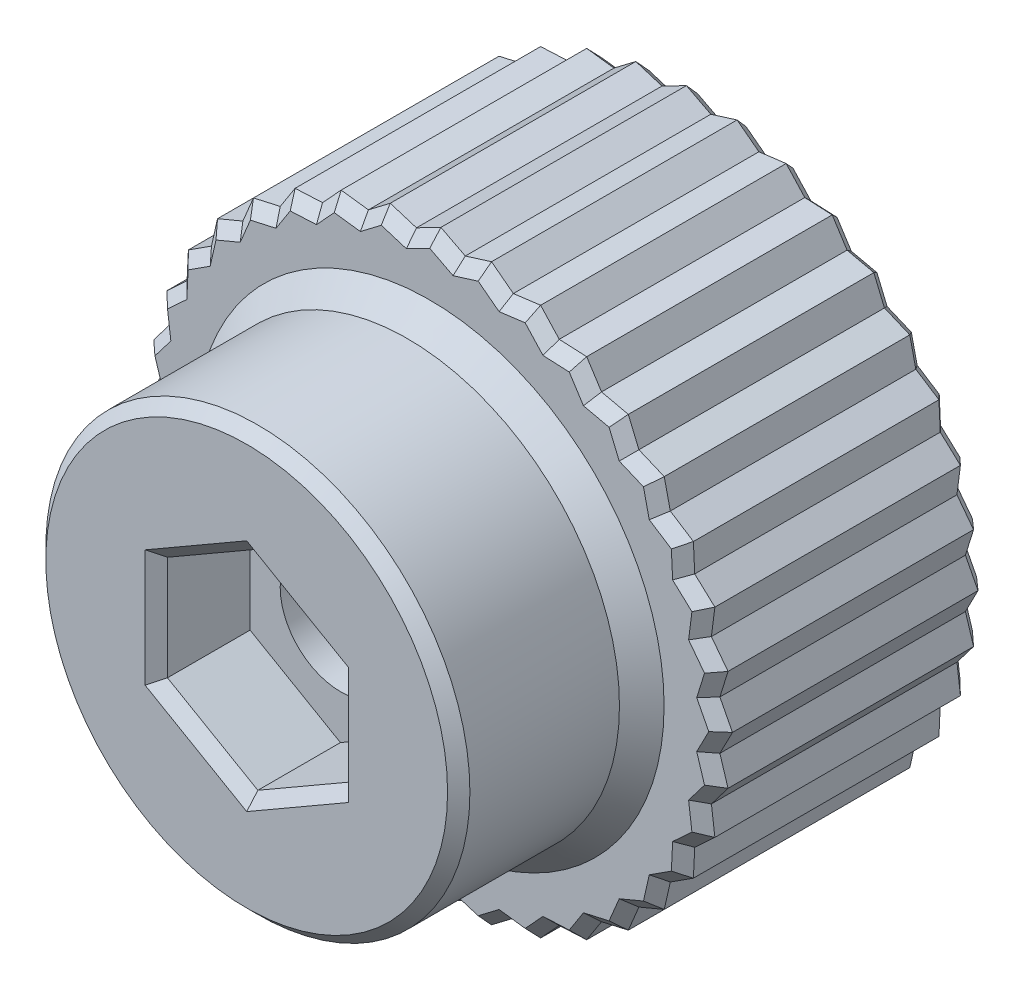
from build123d import *

# Parameters (mm, degrees)
SKETCH1_R           = 12.5
BOSS_EXTRUDE1_DEPTH = 12
SKETCH5_R           = 12.090152216
BOSS_EXTRUDE4_DEPTH = 12
SKETCH8_R           = 9.5
BOSS_EXTRUDE5_DEPTH = 8.2
SKETCH9_R           = 2.7
CUT_EXTRUDE2_DEPTH  = 21.2
SKETCH9_3_R         = 4.4
SKETCH9_3_R_2       = 2.7
CUT_EXTRUDE3_DEPTH  = 5.2
CUT_EXTRUDE4_DEPTH  = 4.2
CHAMFER2_SIZE       = 0.5
CHAMFER3_SIZE       = 1
SKETCH11_R          = 2.7
BOSS_EXTRUDE6_DEPTH = 0.2


with BuildPart() as part:
    # Sketch1 → Boss-Extrude1 (new body)
    with BuildSketch(Plane.XY):
        Circle(SKETCH1_R)
    extrude(amount=BOSS_EXTRUDE1_DEPTH)

    # Sketch5 → Boss-Extrude4 (add)
    with BuildSketch(Plane.XY.offset(12)):
        Polygon((0, 13.063196798), (1.093562728, 12.499479176), (2.268400319, 12.864737486), (3.247460833, 12.119688826), (4.467876441, 12.275389635), (5.302686485, 11.371647864), (6.531598399, 11.313060282), (7.196792691, 10.278085136), (8.396861045, 10.006989317), (8.872227993, 8.872227993), (10.006989317, 8.396861045), (10.278085136, 7.196792691), (11.313060282, 6.531598399), (11.371647864, 5.302686485), (12.275389635, 4.467876441), (12.119688826, 3.247460833), (12.864737486, 2.268400319), (12.499479176, 1.093562728), (13.063196798, 0), (12.499479176, -1.093562728), (12.864737486, -2.268400319), (12.119688826, -3.247460833), (12.275389635, -4.467876441), (11.371647864, -5.302686485), (11.313060282, -6.531598399), (10.278085136, -7.196792691), (10.006989317, -8.396861045), (8.872227993, -8.872227993), (8.396861045, -10.006989317), (7.196792691, -10.278085136), (6.531598399, -11.313060282), (5.302686485, -11.371647864), (4.467876441, -12.275389635), (3.247460833, -12.119688826), (2.268400319, -12.864737486), (1.093562728, -12.499479176), (0, -13.063196798), (-1.093562728, -12.499479176), (-2.268400319, -12.864737486), (-3.247460833, -12.119688826), (-4.467876441, -12.275389635), (-5.302686485, -11.371647864), (-6.531598399, -11.313060282), (-7.196792691, -10.278085136), (-8.396861045, -10.006989317), (-8.872227993, -8.872227993), (-10.006989317, -8.396861045), (-10.278085136, -7.196792691), (-11.313060282, -6.531598399), (-11.371647864, -5.302686485), (-12.275389635, -4.467876441), (-12.119688826, -3.247460833), (-12.864737486, -2.268400319), (-12.499479176, -1.093562728), (-13.063196798, 0), (-12.499479176, 1.093562728), (-12.864737486, 2.268400319), (-12.119688826, 3.247460833), (-12.275389635, 4.467876441), (-11.371647864, 5.302686485), (-11.313060282, 6.531598399), (-10.278085136, 7.196792691), (-10.006989317, 8.396861045), (-8.872227993, 8.872227993), (-8.396861045, 10.006989317), (-7.196792691, 10.278085136), (-6.531598399, 11.313060282), (-5.302686485, 11.371647864), (-4.467876441, 12.275389635), (-3.247460833, 12.119688826), (-2.268400319, 12.864737486), (-1.093562728, 12.499479176), align=None)
        Circle(SKETCH5_R, mode=Mode.SUBTRACT)
    extrude(amount=-BOSS_EXTRUDE4_DEPTH)

    # Sketch8 → Boss-Extrude5 (add)
    with BuildSketch(Plane.XY.offset(12)):
        Circle(SKETCH8_R)
    extrude(amount=BOSS_EXTRUDE5_DEPTH)

    # Sketch9 → Cut-Extrude2 (cut, through all)
    with BuildSketch(Plane(origin=(0, 0, 0), x_dir=(-1, 0, 0), z_dir=(0, 0, -1))):
        Circle(SKETCH9_R)
    extrude(amount=-CUT_EXTRUDE2_DEPTH, mode=Mode.SUBTRACT)

    # Sketch9_3 → Cut-Extrude3 (cut)
    with BuildSketch(Plane(origin=(0, 0, 0), x_dir=(-1, 0, 0), z_dir=(0, 0, -1))):
        Circle(SKETCH9_3_R)
        Circle(SKETCH9_3_R_2, mode=Mode.SUBTRACT)
    extrude(amount=-CUT_EXTRUDE3_DEPTH, mode=Mode.SUBTRACT)

    # Sketch10 → Cut-Extrude4 (cut)
    with BuildSketch(Plane.XY.offset(20.2)):
        Polygon((0, 4.67653718), (-4.05, 2.33826859), (-4.05, -2.33826859), (0, -4.67653718), (4.05, -2.33826859), (4.05, 2.33826859), align=None)
    extrude(amount=-CUT_EXTRUDE4_DEPTH, mode=Mode.SUBTRACT)

    # Chamfer2
    chamfer2_edges = [part.edges().sort_by_distance(p)[0] for p in [
        (-0.546781364, 12.781337987, 12),
        (-1.680981523, 12.682108331, 12),
        (-2.757930576, 12.492213156, 12),
        (-3.857668637, 12.197539231, 12),
        (-4.885281463, 11.82351875, 12),
        (-9.5, 0, 20.2),
        (-5.917142442, 11.342354073, 12),
        (-6.864195545, 10.795572709, 12),
        (-7.796826868, 10.142537226, 12),
        (4.4, 0, 0),
        (-8.634544519, 9.439608655, 12),
        (-9.439608655, 8.634544519, 12),
        (-10.142537226, 7.796826868, 12),
        (2.025, 3.507402885, 20.2),
        (-2.025, 3.507402885, 20.2),
        (-4.05, 0, 20.2),
        (-10.795572709, 6.864195545, 12),
        (-2.025, -3.507402885, 20.2),
        (2.025, -3.507402885, 20.2),
        (4.05, 0, 20.2),
        (-11.342354073, 5.917142442, 12),
        (-11.82351875, 4.885281463, 12),
        (-12.197539231, 3.857668637, 12),
        (-12.492213156, 2.757930576, 12),
        (-12.682108331, 1.680981523, 12),
        (-12.781337987, 0.546781364, 12),
        (-12.781337987, -0.546781364, 12),
        (-12.682108331, -1.680981523, 12),
        (-12.492213156, -2.757930576, 12),
        (-12.197539231, -3.857668637, 12),
        (-11.82351875, -4.885281463, 12),
        (-11.342354073, -5.917142442, 12),
        (-10.795572709, -6.864195545, 12),
        (-10.142537226, -7.796826868, 12),
        (-9.439608655, -8.634544519, 12),
        (-8.634544519, -9.439608655, 12),
        (-7.796826868, -10.142537226, 12),
        (-6.864195545, -10.795572709, 12),
        (-5.917142442, -11.342354073, 12),
        (-4.885281463, -11.82351875, 12),
        (-3.857668637, -12.197539231, 12),
        (-2.757930576, -12.492213156, 12),
        (-1.680981523, -12.682108331, 12),
        (-0.546781364, -12.781337987, 12),
        (0.546781364, -12.781337987, 12),
        (1.680981523, -12.682108331, 12),
        (2.757930576, -12.492213156, 12),
        (3.857668637, -12.197539231, 12),
        (4.885281463, -11.82351875, 12),
        (5.917142442, -11.342354073, 12),
        (6.864195545, -10.795572709, 12),
        (7.796826868, -10.142537226, 12),
        (8.634544519, -9.439608655, 12),
        (9.439608655, -8.634544519, 12),
        (10.142537226, -7.796826868, 12),
        (10.795572709, -6.864195545, 12),
        (11.342354073, -5.917142442, 12),
        (11.82351875, -4.885281463, 12),
        (12.197539231, -3.857668637, 12),
        (12.492213156, -2.757930576, 12),
        (12.682108331, -1.680981523, 12),
        (12.781337987, -0.546781364, 12),
        (12.781337987, 0.546781364, 12),
        (12.682108331, 1.680981523, 12),
        (12.492213156, 2.757930576, 12),
        (12.197539231, 3.857668637, 12),
        (11.82351875, 4.885281463, 12),
        (11.342354073, 5.917142442, 12),
        (10.795572709, 6.864195545, 12),
        (10.142537226, 7.796826868, 12),
        (9.439608655, 8.634544519, 12),
        (8.634544519, 9.439608655, 12),
        (7.796826868, 10.142537226, 12),
        (6.864195545, 10.795572709, 12),
        (5.917142442, 11.342354073, 12),
        (4.885281463, 11.82351875, 12),
        (3.857668637, 12.197539231, 12),
        (2.757930576, 12.492213156, 12),
        (1.680981523, 12.682108331, 12),
        (0.546781364, 12.781337987, 12),
        (-0.546781364, 12.781337987, 0),
        (0.546781364, 12.781337987, 0),
        (1.680981523, 12.682108331, 0),
        (2.757930576, 12.492213156, 0),
        (3.857668637, 12.197539231, 0),
        (4.885281463, 11.82351875, 0),
        (5.917142442, 11.342354073, 0),
        (6.864195545, 10.795572709, 0),
        (7.796826868, 10.142537226, 0),
        (8.634544519, 9.439608655, 0),
        (9.439608655, 8.634544519, 0),
        (10.142537226, 7.796826868, 0),
        (10.795572709, 6.864195545, 0),
        (11.342354073, 5.917142442, 0),
        (11.82351875, 4.885281463, 0),
        (12.197539231, 3.857668637, 0),
        (12.492213156, 2.757930576, 0),
        (12.682108331, 1.680981523, 0),
        (12.781337987, 0.546781364, 0),
        (12.781337987, -0.546781364, 0),
        (12.682108331, -1.680981523, 0),
        (12.492213156, -2.757930576, 0),
        (12.197539231, -3.857668637, 0),
        (11.82351875, -4.885281463, 0),
        (11.342354073, -5.917142442, 0),
        (10.795572709, -6.864195545, 0),
        (10.142537226, -7.796826868, 0),
        (9.439608655, -8.634544519, 0),
        (8.634544519, -9.439608655, 0),
        (7.796826868, -10.142537226, 0),
        (6.864195545, -10.795572709, 0),
        (5.917142442, -11.342354073, 0),
        (4.885281463, -11.82351875, 0),
        (3.857668637, -12.197539231, 0),
        (2.757930576, -12.492213156, 0),
        (1.680981523, -12.682108331, 0),
        (0.546781364, -12.781337987, 0),
        (-0.546781364, -12.781337987, 0),
        (-1.680981523, -12.682108331, 0),
        (-2.757930576, -12.492213156, 0),
        (-3.857668637, -12.197539231, 0),
        (-4.885281463, -11.82351875, 0),
        (-5.917142442, -11.342354073, 0),
        (-6.864195545, -10.795572709, 0),
        (-7.796826868, -10.142537226, 0),
        (-8.634544519, -9.439608655, 0),
        (-9.439608655, -8.634544519, 0),
        (-10.142537226, -7.796826868, 0),
        (-10.795572709, -6.864195545, 0),
        (-11.342354073, -5.917142442, 0),
        (-11.82351875, -4.885281463, 0),
        (-12.197539231, -3.857668637, 0),
        (-12.492213156, -2.757930576, 0),
        (-12.682108331, -1.680981523, 0),
        (-12.781337987, -0.546781364, 0),
        (-12.781337987, 0.546781364, 0),
        (-12.682108331, 1.680981523, 0),
        (-12.492213156, 2.757930576, 0),
        (-12.197539231, 3.857668637, 0),
        (-11.82351875, 4.885281463, 0),
        (-11.342354073, 5.917142442, 0),
        (-10.795572709, 6.864195545, 0),
        (-10.142537226, 7.796826868, 0),
        (-9.439608655, 8.634544519, 0),
        (-8.634544519, 9.439608655, 0),
        (-7.796826868, 10.142537226, 0),
        (-6.864195545, 10.795572709, 0),
        (-5.917142442, 11.342354073, 0),
        (-4.885281463, 11.82351875, 0),
        (-3.857668637, 12.197539231, 0),
        (-2.757930576, 12.492213156, 0),
        (-1.680981523, 12.682108331, 0),
    ]]
    chamfer(chamfer2_edges, length=CHAMFER2_SIZE)

    # Chamfer3
    chamfer3_edges = [part.edges().sort_by_distance(p)[0] for p in [
        (-9.5, 0, 12),
    ]]
    chamfer(chamfer3_edges, length=CHAMFER3_SIZE)

    # Sketch11 → Boss-Extrude6 (add)
    with BuildSketch(Plane(origin=(0, 0, 5.2), x_dir=(-1, 0, 0), z_dir=(0, 0, -1))):
        Circle(SKETCH11_R)
    extrude(amount=-BOSS_EXTRUDE6_DEPTH)


solid = part.part
